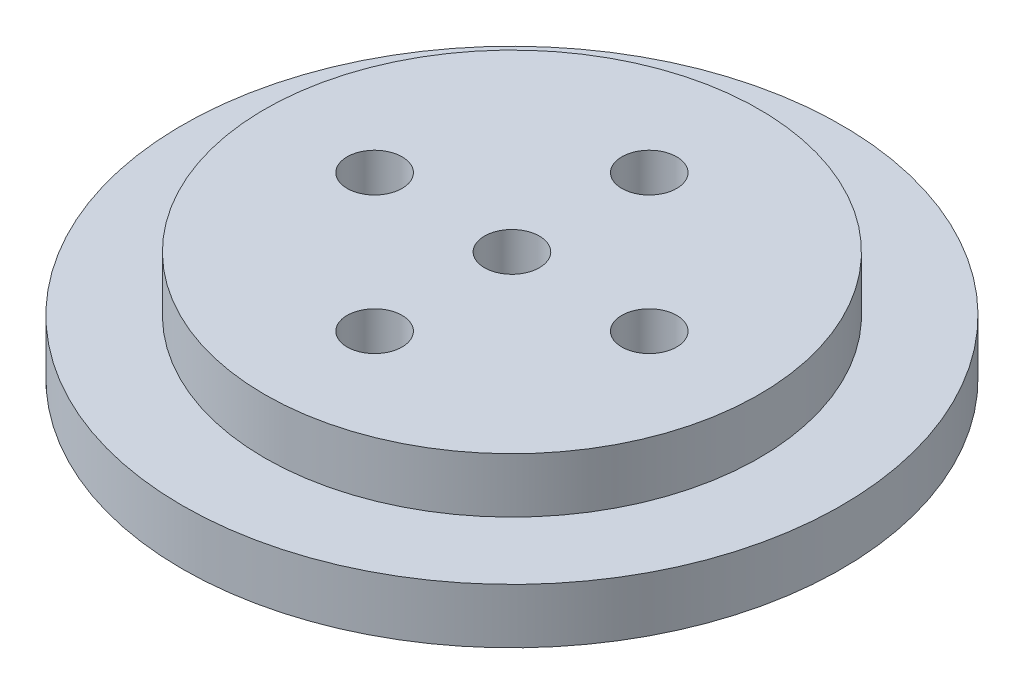
from build123d import *

# Parameters (mm, degrees)
CROQUIS1_R              = 45
CROQUIS1_R_2            = 5
SALIENTE_EXTRUIR1_DEPTH = 30
SALIENTE_EXTRUIR2_START = -10
CROQUIS2_R              = 60
CROQUIS2_R_2            = 45
SALIENTE_EXTRUIR2_DEPTH = 10


with BuildPart() as part:
    # Croquis1 → Saliente-Extruir1 (new body)
    with BuildSketch(Plane(origin=(0, 0, 0), x_dir=(1, 0, 0), z_dir=(0, 1, 0))):
        Circle(CROQUIS1_R)
        Circle(CROQUIS1_R_2, mode=Mode.SUBTRACT)
        with Locations((0, 25)):
            Circle(CROQUIS1_R_2, mode=Mode.SUBTRACT)
        with Locations((25, 0)):
            Circle(CROQUIS1_R_2, mode=Mode.SUBTRACT)
        with Locations((0, -25)):
            Circle(CROQUIS1_R_2, mode=Mode.SUBTRACT)
        with Locations((-25, 0)):
            Circle(CROQUIS1_R_2, mode=Mode.SUBTRACT)
    extrude(amount=SALIENTE_EXTRUIR1_DEPTH)

    # Croquis2 → Saliente-Extruir2 (add)
    with BuildSketch(Plane(origin=(0, 30, 0), x_dir=(1, 0, 0), z_dir=(0, 1, 0)).offset(SALIENTE_EXTRUIR2_START)):
        Circle(CROQUIS2_R)
        Circle(CROQUIS2_R_2, mode=Mode.SUBTRACT)
    extrude(amount=-SALIENTE_EXTRUIR2_DEPTH)


solid = part.part
